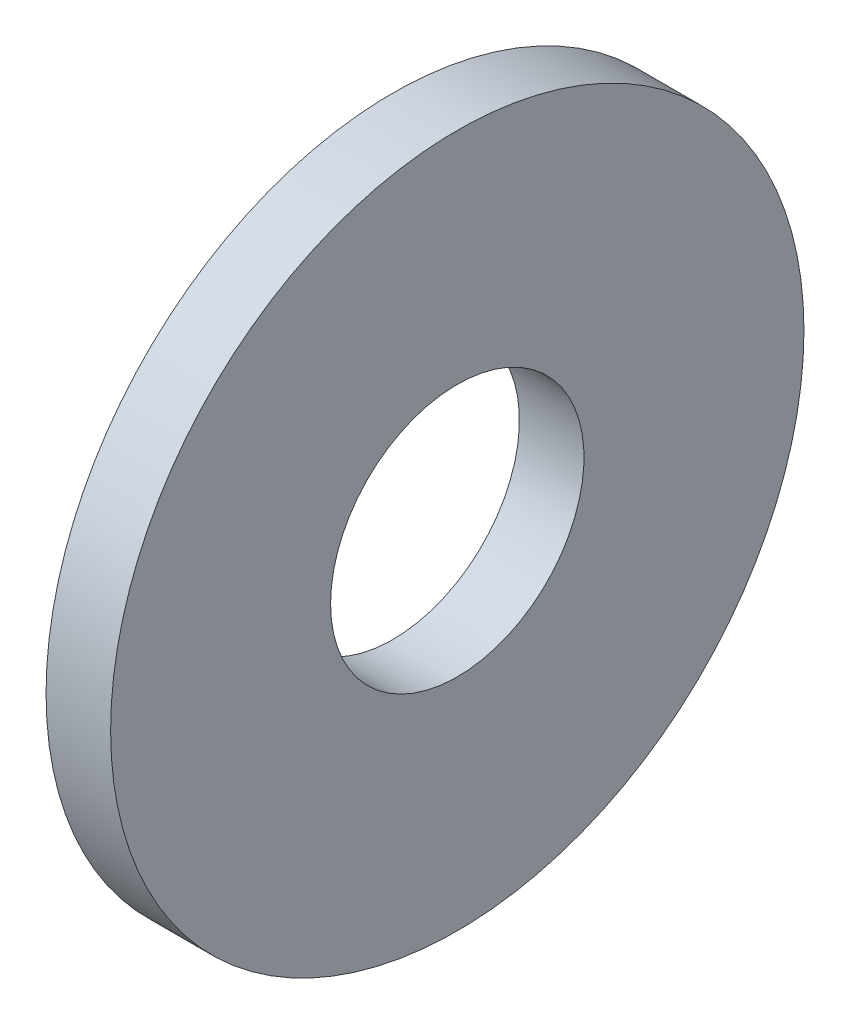
from build123d import *

# Parameters (mm, degrees)
SKETCH1_W = 1.75
SKETCH1_H = 5.965


with BuildPart() as part:
    # Sketch1 → Base-Revolve (revolve)
    with BuildSketch(Plane.XY):
        with Locations((-0.875, 6.4175)):
            Rectangle(SKETCH1_W, SKETCH1_H)
    revolve(axis=Axis((-34.925, 0, 0), (1, 0, 0)))


solid = part.part
